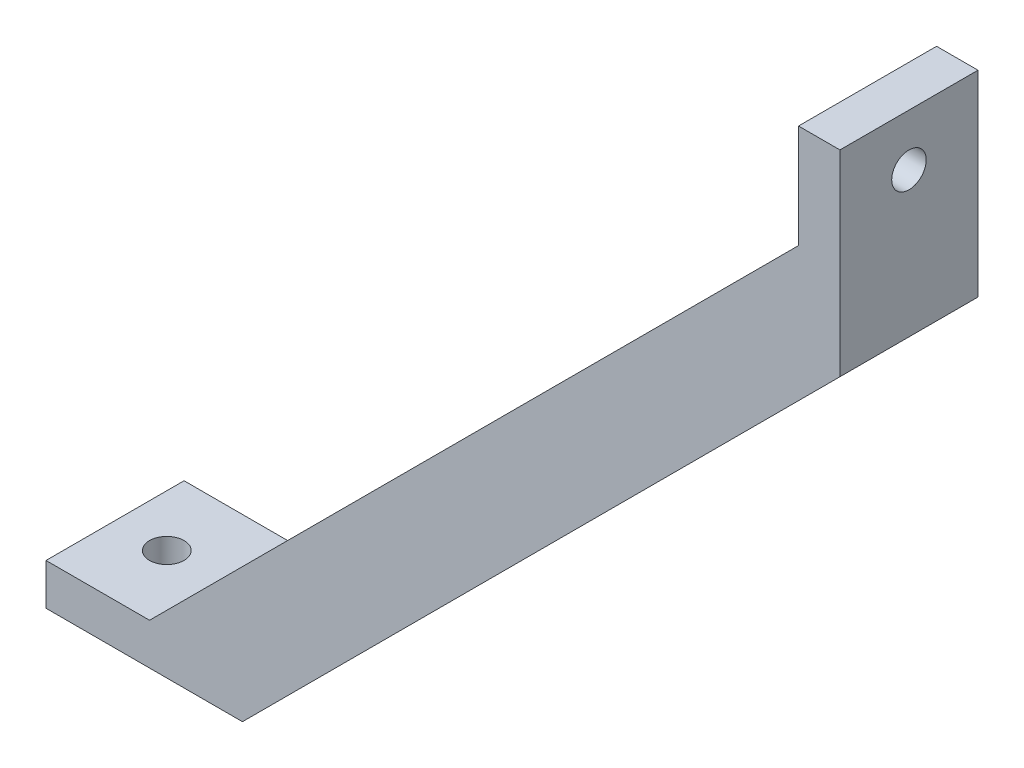
from build123d import *

# Parameters (mm, degrees)
BOSS_EXTRUDE1_DEPTH = 20
SKETCH3_R           = 2.5
CUT_EXTRUDE1_DEPTH  = 20
SKETCH4_R           = 2.5
CUT_EXTRUDE2_DEPTH  = 20


with BuildPart() as part:
    # Sketch2 → Boss-Extrude1 (new body)
    with BuildSketch(Plane.XY):
        Polygon((-115, 0), (-115, 6), (-100, 6), (-6, 100), (-6, 115), (0, 115), (0, 86.541134144), (-86.541134144, 0), align=None)
    extrude(amount=BOSS_EXTRUDE1_DEPTH)

    # Sketch3 → Cut-Extrude1 (cut)
    with BuildSketch(Plane.ZY.offset(6)):
        with Locations((10, 107.5)):
            Circle(SKETCH3_R)
    extrude(amount=-CUT_EXTRUDE1_DEPTH, mode=Mode.SUBTRACT)

    # Sketch4 → Cut-Extrude2 (cut)
    with BuildSketch(Plane(origin=(0, 6, 0), x_dir=(1, 0, 0), z_dir=(0, 1, 0))):
        with Locations((-107.5, -10)):
            Circle(SKETCH4_R)
    extrude(amount=-CUT_EXTRUDE2_DEPTH, mode=Mode.SUBTRACT)


solid = part.part
